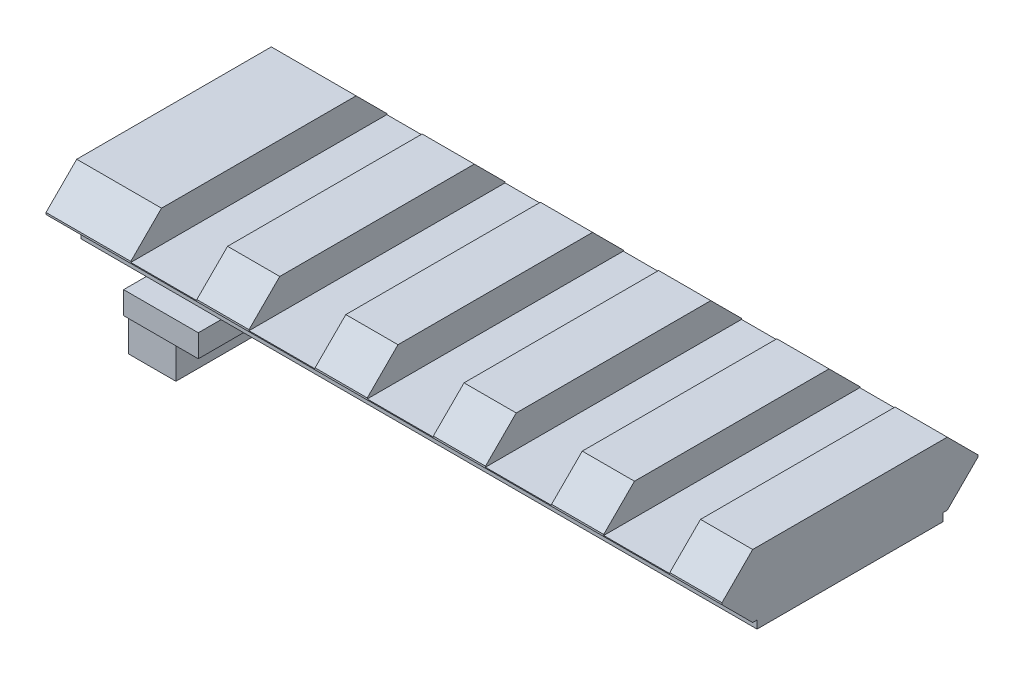
from build123d import *

# Parameters (mm, degrees)
BOSS_EXTRUDE1_DEPTH             = 57
SKETCH2_W                       = 5.57
SKETCH2_H                       = 21.59
CUT_EXTRUDE1_DEPTH              = 2.667
LPATTERN1_COUNT                 = 5
LPATTERN1_PITCH                 = 9.97
SKETCH4_W                       = 6.3
SKETCH4_H                       = 19.5
BOSS_EXTRUDE3_DEPTH             = 1.9
SKETCH3_W                       = 4
SKETCH3_H                       = 8.35
SKETCH3_H_2                     = 7.35
BOSS_EXTRUDE2_DEPTH             = 3
TAP_DRILL_FOR_M2X0_4_TAP1_D     = 1.6
TAP_DRILL_FOR_M2X0_4_TAP1_DEPTH = 5.233
TAP_DRILL_FOR_M2X0_4_TAP1_TIP   = 0.480688495


with BuildPart() as part:
    # Sketch1 → Boss-Extrude1 (new body)
    with BuildSketch(Plane(origin=(0, 0, 0), x_dir=(0, 0, -1), z_dir=(1, 0, 0))):
        Polygon((-7.8359, -6), (7.8359, -6), (7.8359, -5.334), (8.2042, -5.334), (10.795, -2.7432), (10.795, -2.5908), (8.2042, 0), (-8.2042, 0), (-10.795, -2.5908), (-10.795, -2.7432), (-8.2042, -5.334), (-7.8359, -5.334), align=None)
    extrude(amount=BOSS_EXTRUDE1_DEPTH)

    # Sketch2 → Cut-Extrude1 (cut)
    with BuildSketch(Plane(origin=(0, 0, 0), x_dir=(1, 0, 0), z_dir=(0, 1, 0))):
        with Locations((49.815, 0)):
            Rectangle(SKETCH2_W, SKETCH2_H)
    cut_extrude1 = extrude(amount=-CUT_EXTRUDE1_DEPTH, mode=Mode.SUBTRACT)

    # LPattern1: Cut-Extrude1 ×5
    with Locations(*[(-i * LPATTERN1_PITCH, 0, 0) for i in range(1, LPATTERN1_COUNT)]):
        add(cut_extrude1, mode=Mode.SUBTRACT)

    # Sketch4 → Boss-Extrude3 (add)
    with BuildSketch(Plane.XZ.offset(6)):
        with Locations((8.65, 0)):
            Rectangle(SKETCH4_W, SKETCH4_H)
    extrude(amount=BOSS_EXTRUDE3_DEPTH)

    # Sketch3 → Boss-Extrude2 (add)
    with BuildSketch(Plane.XZ.offset(7.9)):
        with Locations((7.5, -5.165)):
            Rectangle(SKETCH3_W, SKETCH3_H)
        with Locations((7.5, 5.665)):
            Rectangle(SKETCH3_W, SKETCH3_H_2)
    extrude(amount=BOSS_EXTRUDE2_DEPTH)

    # Tap Drill for M2x0.4 Tap1
    with Locations(Plane(origin=(0, -10.9, 0), x_dir=(-1, 0, 0), z_dir=(0, -1, 0))):
        with Locations((-7.5, -6.24), (-7.5, 3.56)):
            Hole(TAP_DRILL_FOR_M2X0_4_TAP1_D / 2, depth=TAP_DRILL_FOR_M2X0_4_TAP1_DEPTH)
            with Locations((0, 0, -(TAP_DRILL_FOR_M2X0_4_TAP1_DEPTH + TAP_DRILL_FOR_M2X0_4_TAP1_TIP / 2))):  # 118° drill point
                Cone(0, TAP_DRILL_FOR_M2X0_4_TAP1_D / 2, TAP_DRILL_FOR_M2X0_4_TAP1_TIP, mode=Mode.SUBTRACT)


solid = part.part
